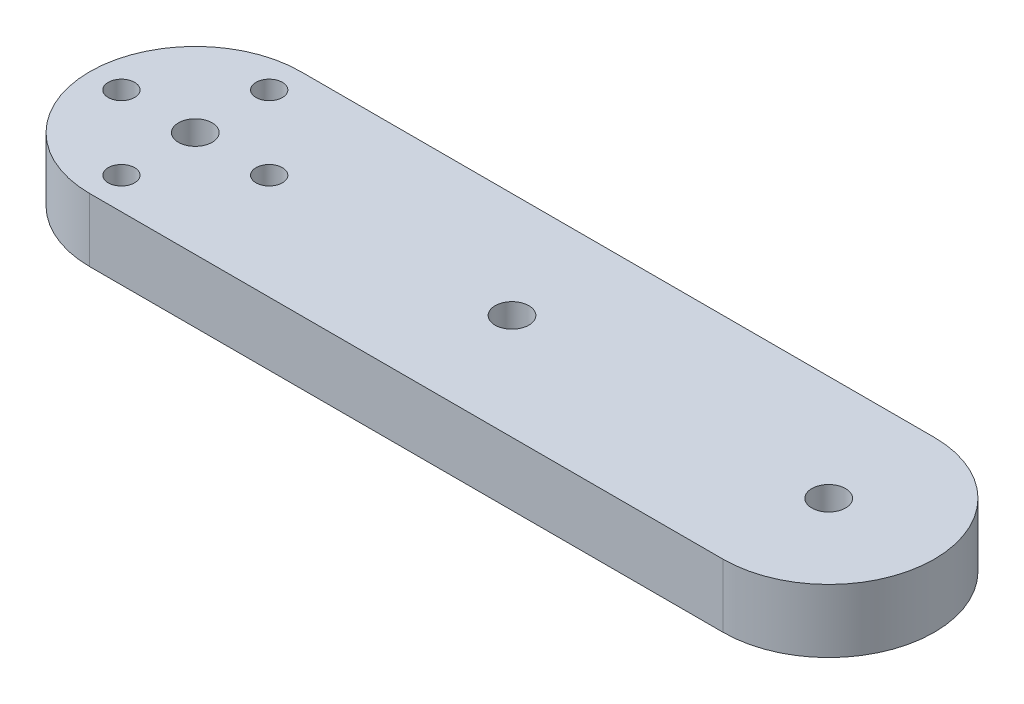
from build123d import *

# Parameters (mm, degrees)
SKETCH1_R           = 1.6
SKETCH1_R_2         = 1.25
BOSS_EXTRUDE1_DEPTH = 6


with BuildPart() as part:
    # Sketch1 → Boss-Extrude1 (new body)
    with BuildSketch(Plane(origin=(0, 0, 0), x_dir=(1, 0, 0), z_dir=(0, 1, 0))):
        with BuildLine():
            Line((0, 0), (-60, 0))
            ThreePointArc((-60, 0), (-70, 10), (-60, 20))
            Line((-60, 20), (0, 20))
            ThreePointArc((0, 20), (10, 10), (0, 0))
        make_face()
        with Locations((-60, 10)):
            Circle(SKETCH1_R, mode=Mode.SUBTRACT)
        with Locations((-60, 17)):
            Circle(SKETCH1_R_2, mode=Mode.SUBTRACT)
        with Locations((-60, 3)):
            Circle(SKETCH1_R_2, mode=Mode.SUBTRACT)
        with Locations((-67, 10)):
            Circle(SKETCH1_R_2, mode=Mode.SUBTRACT)
        with Locations((-53, 10)):
            Circle(SKETCH1_R_2, mode=Mode.SUBTRACT)
        with Locations((0, 10)):
            Circle(SKETCH1_R, mode=Mode.SUBTRACT)
        with Locations((-30, 10)):
            Circle(SKETCH1_R, mode=Mode.SUBTRACT)
    extrude(amount=BOSS_EXTRUDE1_DEPTH)


solid = part.part
